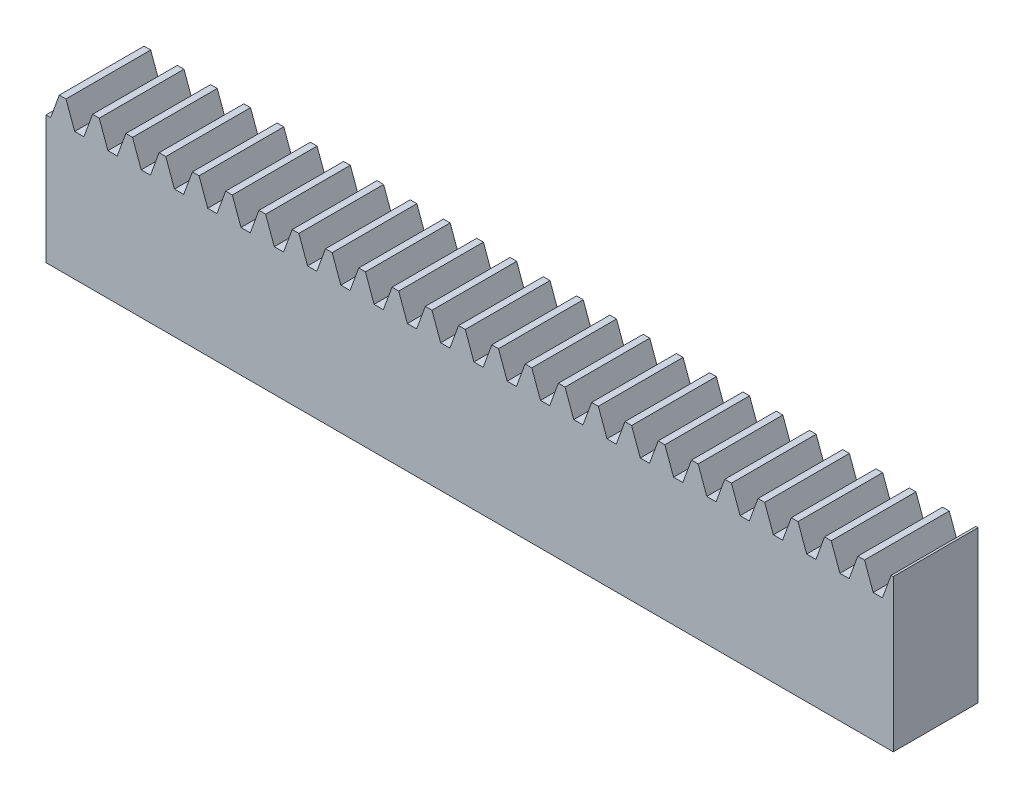
from build123d import *

# Parameters (mm, degrees)
BLANKSKE_W        = 120
BLANKSKE_H        = 21.5
BLANK_DEPTH       = 12
TOOTHCUTSIM_DEPTH = 123.5
TEETHCUTS_COUNT   = 26
TEETHCUTS_PITCH   = 4.712388975


with BuildPart() as part:
    # BlankSke → Blank (new body)
    with BuildSketch(Plane.XY):
        with Locations((60, 10.75)):
            Rectangle(BLANKSKE_W, BLANKSKE_H)
    extrude(amount=-BLANK_DEPTH)

    # TooCutSkeSim → ToothCutSim (cut, through all)
    with BuildSketch(Plane.XY):
        Polygon((0.654653055, 18.125), (-0.654653055, 18.125), (-1.892297439, 21.5254), (1.892297439, 21.5254), align=None)
    toothcutsim = extrude(amount=-TOOTHCUTSIM_DEPTH, mode=Mode.SUBTRACT)

    # TeethCuts: ToothCutSim ×26
    with Locations(*[(i * TEETHCUTS_PITCH, 0, 0) for i in range(1, TEETHCUTS_COUNT)]):
        add(toothcutsim, mode=Mode.SUBTRACT)


solid = part.part
